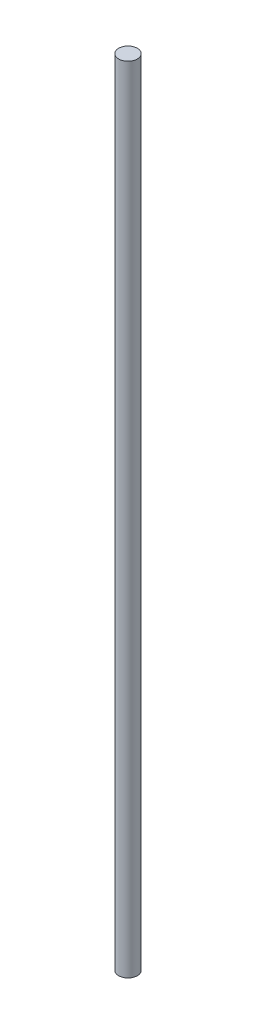
from build123d import *

# Parameters (mm, degrees)
CROQUIS1_R = 6.35


with BuildPart() as part:
    # Barrer1: sweep along a path in Croquis2
    with BuildLine(Plane.XY) as barrer1_path:
        Line((0, 0), (0, 540))
    # Croquis1 → Barrer1 (sweep)
    with BuildSketch(Plane(origin=(0, 0, 0), x_dir=(1, 0, 0), z_dir=(0, 1, 0))):
        Circle(CROQUIS1_R)
    sweep(path=barrer1_path.line)


solid = part.part
